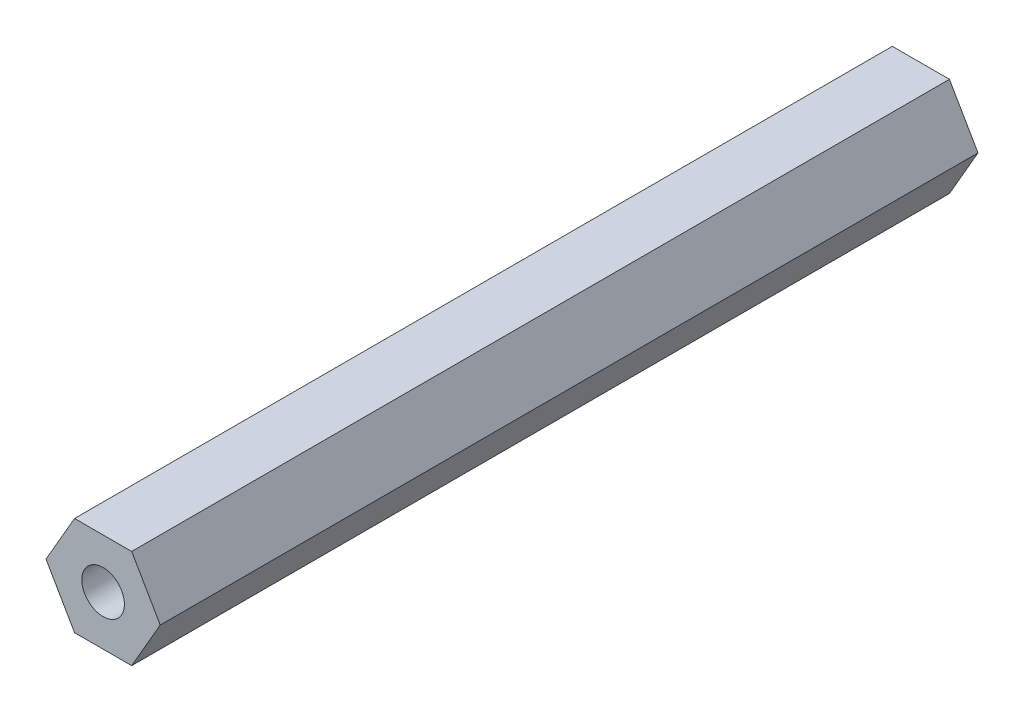
from build123d import *

# Parameters (mm, degrees)
SALIENTE_EXTRUIR1_DEPTH = 65.3
CROQUIS2_R              = 1.7
CORTAR_EXTRUIR1_DEPTH   = 65.3


with BuildPart() as part:
    # Croquis1 → Saliente-Extruir1 (new body)
    with BuildSketch(Plane.XY):
        Polygon((4.561067127, 0), (2.280533563, 3.95), (-2.280533563, 3.95), (-4.561067127, 0), (-2.280533563, -3.95), (2.280533563, -3.95), align=None)
    extrude(amount=SALIENTE_EXTRUIR1_DEPTH)

    # Croquis2 → Cortar-Extruir1 (cut)
    with BuildSketch(Plane.XY.offset(65.3)):
        Circle(CROQUIS2_R)
    extrude(amount=-CORTAR_EXTRUIR1_DEPTH, mode=Mode.SUBTRACT)


solid = part.part
